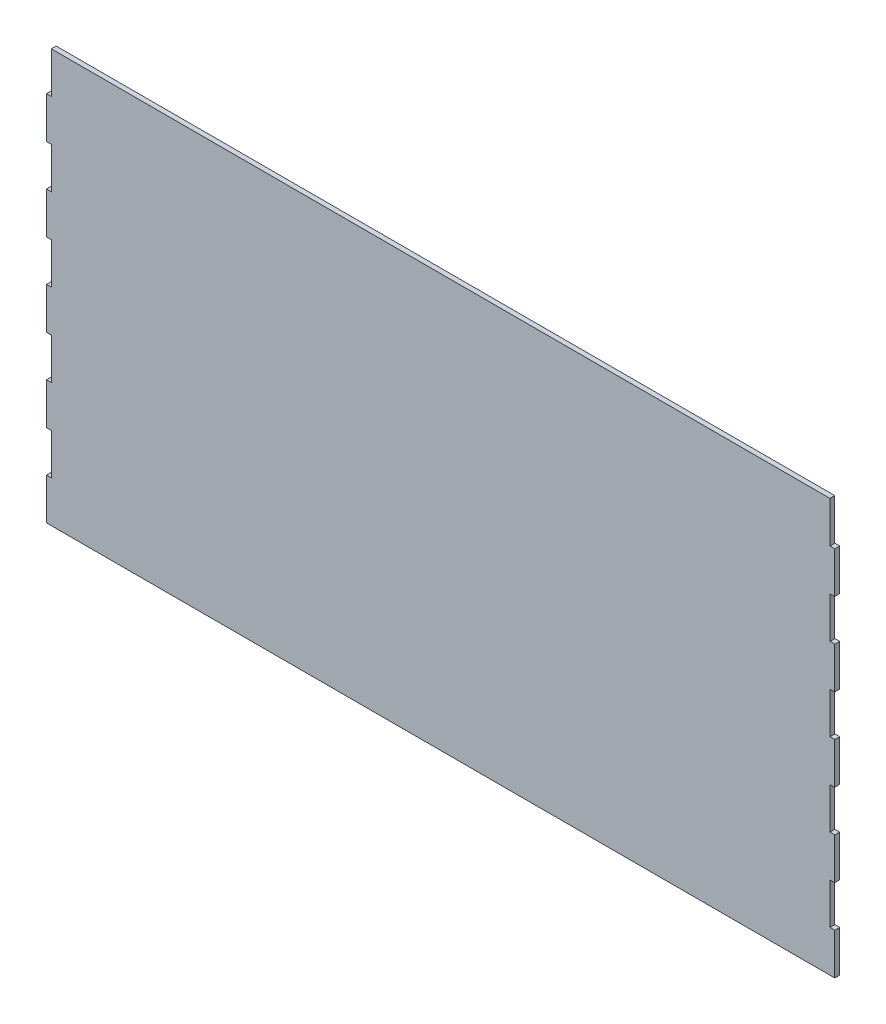
from build123d import *

# Parameters (mm, degrees)
SKETCH1_W           = 977.375
SKETCH1_H           = 512
BOSS_EXTRUDE1_DEPTH = 6
CUT_EXTRUDE3_DEPTH  = 10
LPATTERN1_COUNT     = 5
LPATTERN1_PITCH     = 102.4
SKETCH8_W           = 6
SKETCH8_H           = 0.580661117
CUT_EXTRUDE4_DEPTH  = 10
CUT_EXTRUDE5_DEPTH  = 10
LPATTERN4_COUNT     = 5
LPATTERN4_PITCH     = 102.4
SKETCH11_W          = 6
SKETCH11_H          = 0.733192148
CUT_EXTRUDE6_DEPTH  = 10


with BuildPart() as part:
    # Sketch1 → Boss-Extrude1 (new body)
    with BuildSketch(Plane.XY):
        Rectangle(SKETCH1_W, SKETCH1_H)
    extrude(amount=BOSS_EXTRUDE1_DEPTH)

    # Sketch7 → Cut-Extrude3 (cut)
    with BuildSketch(Plane.XY.offset(6)):
        with BuildLine():
            add(Edge.make_bspline(
                [(488.6875, -204.8), (488.6875, -204.6), (485.6875, -204.6), (482.6875, -204.6), (482.6875, -204.8)],
                knots=[0, 0, 0, 1.570796327, 1.570796327, 3.141592654, 3.141592654, 3.141592654], degree=2, weights=[1, 0.707106781, 1, 0.707106781, 1]))
            Line((488.6875, -204.8), (488.6875, -153.6))
            add(Edge.make_bspline(
                [(482.6875, -153.6), (482.6875, -153.8), (485.6875, -153.8), (488.6875, -153.8), (488.6875, -153.6)],
                knots=[3.141592654, 3.141592654, 3.141592654, 4.71238898, 4.71238898, 6.283185307, 6.283185307, 6.283185307], degree=2, weights=[1, 0.707106781, 1, 0.707106781, 1]))
            Line((482.6875, -153.6), (482.6875, -204.8))
        make_face()
    cut_extrude3 = extrude(amount=-CUT_EXTRUDE3_DEPTH, mode=Mode.SUBTRACT)

    # LPattern1: Cut-Extrude3 ×5
    with Locations(*[(0, i * LPATTERN1_PITCH, 0) for i in range(1, LPATTERN1_COUNT)]):
        add(cut_extrude3, mode=Mode.SUBTRACT)

    # Sketch8 → Cut-Extrude4 (cut)
    with BuildSketch(Plane.XY.offset(6)):
        with Locations((485.6875, 255.709669442)):
            Rectangle(SKETCH8_W, SKETCH8_H)
    extrude(amount=-CUT_EXTRUDE4_DEPTH, mode=Mode.SUBTRACT)

    # Sketch10 → Cut-Extrude5 (cut)
    with BuildSketch(Plane.XY.offset(6)):
        with BuildLine():
            Line((-488.6875, -153.6), (-488.6875, -204.8))
            add(Edge.make_bspline(
                [(-482.6875, -204.8), (-482.6875, -204.6), (-485.6875, -204.6), (-488.6875, -204.6), (-488.6875, -204.8)],
                knots=[0, 0, 0, 1.570796327, 1.570796327, 3.141592654, 3.141592654, 3.141592654], degree=2, weights=[1, 0.707106781, 1, 0.707106781, 1]))
            Line((-482.6875, -204.8), (-482.6875, -153.6))
            add(Edge.make_bspline(
                [(-488.6875, -153.6), (-488.6875, -153.8), (-485.6875, -153.8), (-482.6875, -153.8), (-482.6875, -153.6)],
                knots=[3.141592654, 3.141592654, 3.141592654, 4.71238898, 4.71238898, 6.283185307, 6.283185307, 6.283185307], degree=2, weights=[1, 0.707106781, 1, 0.707106781, 1]))
        make_face()
    cut_extrude5 = extrude(amount=-CUT_EXTRUDE5_DEPTH, mode=Mode.SUBTRACT)

    # LPattern4: Cut-Extrude5 ×5
    with Locations(*[(0, i * LPATTERN4_PITCH, 0) for i in range(1, LPATTERN4_COUNT)]):
        add(cut_extrude5, mode=Mode.SUBTRACT)

    # Sketch11 → Cut-Extrude6 (cut)
    with BuildSketch(Plane.XY.offset(6)):
        with Locations((-485.6875, 255.633403926)):
            Rectangle(SKETCH11_W, SKETCH11_H)
    extrude(amount=-CUT_EXTRUDE6_DEPTH, mode=Mode.SUBTRACT)


solid = part.part
